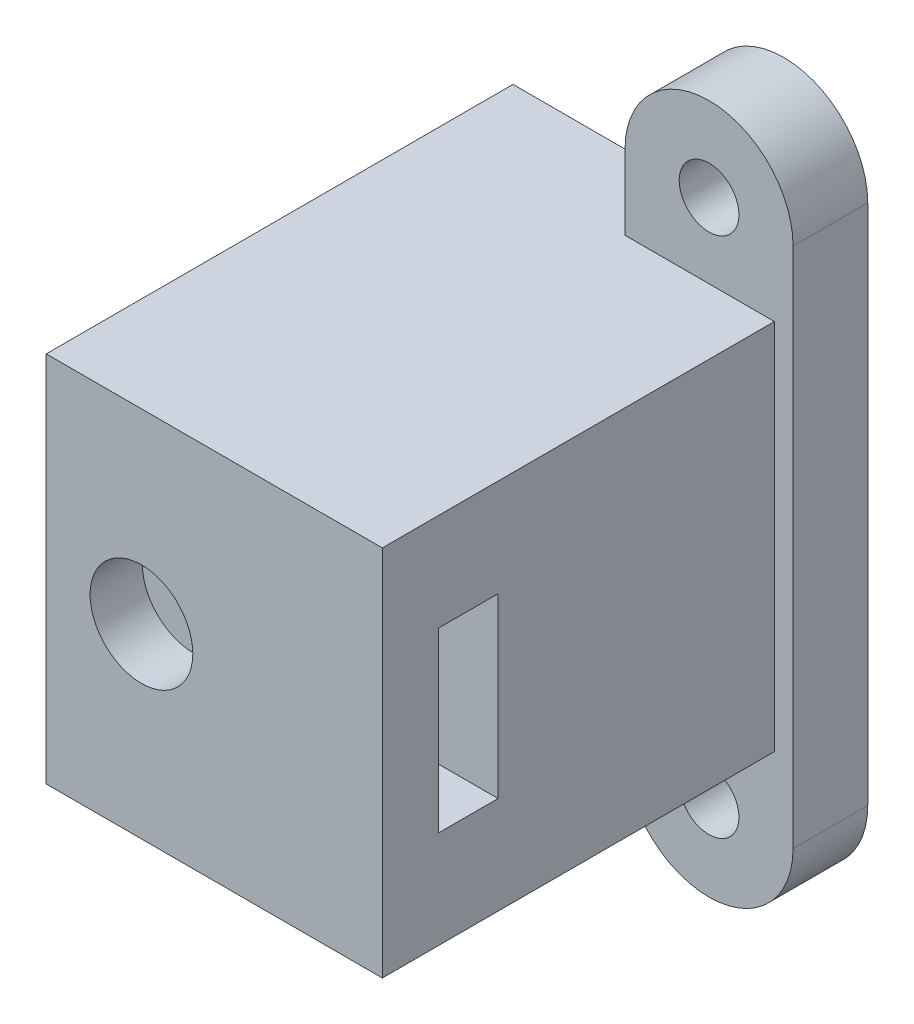
from build123d import *

# Parameters (mm, degrees)
BOSS_EXTRUDE1_DEPTH = 25
SKETCH2_W           = 3.2
SKETCH2_H           = 9.5
CUT_EXTRUDE1_DEPTH  = 55.5
SKETCH3_R           = 2.75
CUT_EXTRUDE2_DEPTH  = 37
CUT_EXTRUDE3_DEPTH  = 17
SKETCH9_W           = 6.2
SKETCH9_H           = 19.95
CUT_EXTRUDE8_DEPTH  = 18
SKETCH10_R          = 2.75
BOSS_EXTRUDE2_DEPTH = 0.2
SKETCH11_R          = 2.75
BOSS_EXTRUDE3_DEPTH = 0.2
SKETCH12_R          = 1.6
BOSS_EXTRUDE4_DEPTH = 4


with BuildPart() as part:
    # Sketch1 → Boss-Extrude1 (new body)
    with BuildSketch(Plane.XY):
        with BuildLine():
            Line((0, 2.395761144), (-1.762956434, 2.395761144))
            ThreePointArc((-1.762956434, 2.395761144), (-2.146371288, 2.574835842), (-2.255146546, 2.983788945))
            Line((-2.255146546, 2.983788945), (-1.936807424, 4.763719442))
            ThreePointArc((-1.936807424, 4.763719442), (-2.424010325, 5.602484354), (-3.331198308, 5.259113989))
            Line((-3.331198308, 5.259113989), (-5, 2.245761144))
            Line((-5, 2.245761144), (-5, 0.895761144))
            Line((-5, 0.895761144), (0, 0.895761144))
            Line((0, 0.895761144), (0, -0.895761144))
            Line((0, -0.895761144), (-5, -0.895761144))
            Line((-5, -0.895761144), (-5, -2.245761144))
            Line((-5, -2.245761144), (-3.331198308, -5.259113989))
            ThreePointArc((-3.331198308, -5.259113989), (-2.424010325, -5.602484354), (-1.936807424, -4.763719442))
            Line((-1.936807424, -4.763719442), (-2.255146546, -2.983788945))
            ThreePointArc((-2.255146546, -2.983788945), (-2.146371288, -2.574835842), (-1.762956434, -2.395761144))
            Line((-1.762956434, -2.395761144), (0, -2.395761144))
            Line((0, -2.395761144), (0, -9.975))
            Line((0, -9.975), (18, -9.975))
            Line((18, -9.975), (18, 9.975))
            Line((18, 9.975), (0, 9.975))
            Line((0, 9.975), (0, 2.395761144))
        make_face()
    extrude(amount=BOSS_EXTRUDE1_DEPTH)

    # Sketch2 → Cut-Extrude1 (cut, symmetric)
    with BuildSketch(Plane.ZY):
        with Locations((20.4, 0)):
            Rectangle(SKETCH2_W, SKETCH2_H)
    extrude(amount=CUT_EXTRUDE1_DEPTH, both=True, mode=Mode.SUBTRACT)

    # Sketch3 → Cut-Extrude2 (cut)
    with BuildSketch(Plane.XY.offset(25)):
        with Locations((5.1, -0.01)):
            Circle(SKETCH3_R)
    extrude(amount=-CUT_EXTRUDE2_DEPTH, mode=Mode.SUBTRACT)

    # Sketch4 → Cut-Extrude3 (cut)
    with BuildSketch(Plane(origin=(0, 0, 0), x_dir=(-1, 0, 0), z_dir=(0, 0, -1))):
        Polygon((-10.555960044, -0.01), (-7.827980022, -4.735), (-2.372019978, -4.735), (0.355960044, -0.01), (-2.372019978, 4.715), (-7.827980022, 4.715), align=None)
    extrude(amount=-CUT_EXTRUDE3_DEPTH, mode=Mode.SUBTRACT)

    # Sketch9 → Cut-Extrude8 (cut)
    with BuildSketch(Plane.ZY):
        with Locations((21.9, 0)):
            Rectangle(SKETCH9_W, SKETCH9_H)
    extrude(amount=CUT_EXTRUDE8_DEPTH, mode=Mode.SUBTRACT)

    # Sketch10 → Boss-Extrude2 (add)
    with BuildSketch(Plane(origin=(0, 0, 17), x_dir=(-1, 0, 0), z_dir=(0, 0, -1))):
        with Locations((-5.1, -0.01)):
            Circle(SKETCH10_R)
    extrude(amount=-BOSS_EXTRUDE2_DEPTH)

    # Sketch11 → Boss-Extrude3 (add)
    with BuildSketch(Plane(origin=(0, 0, 22), x_dir=(-1, 0, 0), z_dir=(0, 0, -1))):
        with Locations((-5.1, -0.01)):
            Circle(SKETCH11_R)
    extrude(amount=-BOSS_EXTRUDE3_DEPTH)

    # Sketch12 → Boss-Extrude4 (add)
    with BuildSketch(Plane(origin=(0, 0, 0), x_dir=(-1, 0, 0), z_dir=(0, 0, -1))):
        with BuildLine():
            Line((-10, 4.48373582), (-12, 0))
            Line((-12, 0), (-10, -4.48373582))
            Line((-10, -4.48373582), (-10, -13.975))
            ThreePointArc((-10, -13.975), (-14.5, -18.475), (-19, -13.975))
            Line((-19, -13.975), (-19, 13.975))
            ThreePointArc((-19, 13.975), (-14.5, 18.475), (-10, 13.975))
            Line((-10, 13.975), (-10, 4.48373582))
        make_face()
        with Locations((-14.5, -13.975)):
            Circle(SKETCH12_R, mode=Mode.SUBTRACT)
        with Locations((-14.5, 13.975)):
            Circle(SKETCH12_R, mode=Mode.SUBTRACT)
    extrude(amount=-BOSS_EXTRUDE4_DEPTH)


solid = part.part
